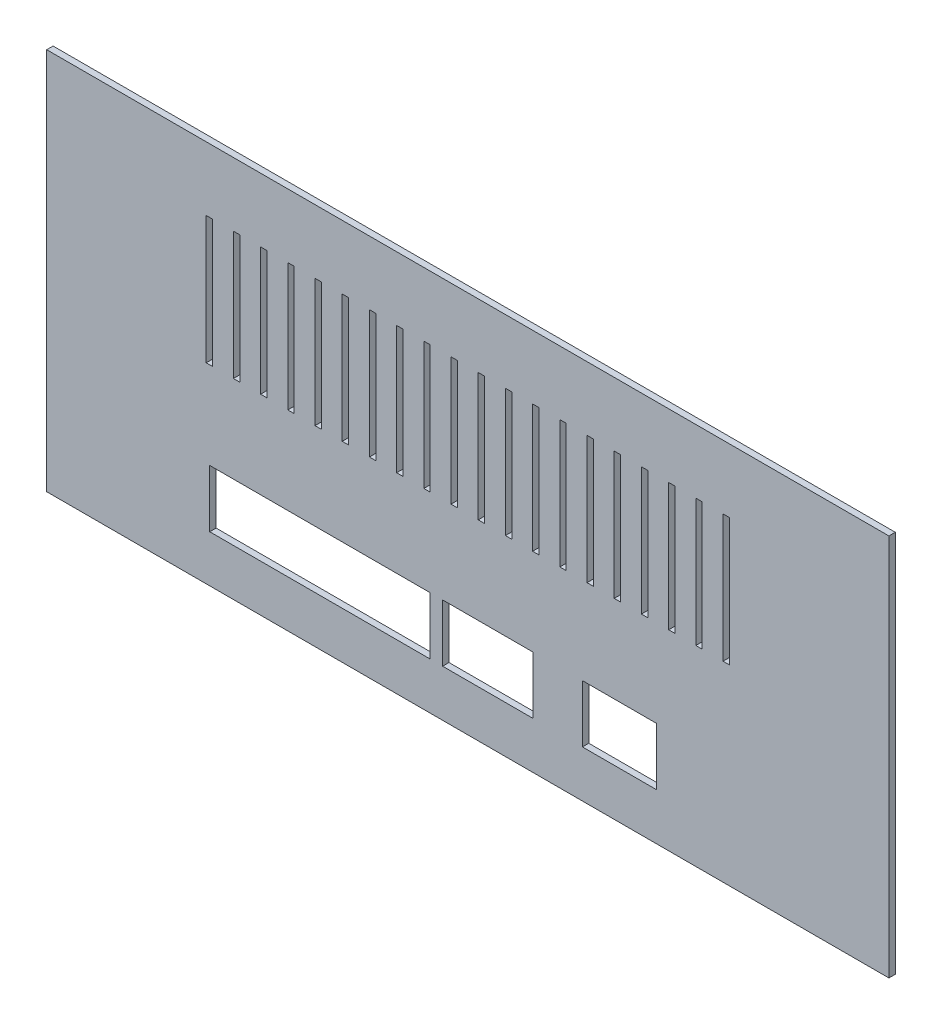
from build123d import *

# Parameters (mm, degrees)
SKETCH1_W           = 132
SKETCH1_H           = 60
BOSS_EXTRUDE1_DEPTH = 1
SKETCH4_W           = 11.62
SKETCH4_H           = 9
SKETCH4_W_2         = 14.16
SKETCH4_W_3         = 34.5
CUT_EXTRUDE3_DEPTH  = 2
SKETCH11_W          = 1
SKETCH11_H          = 20
CUT_EXTRUDE6_DEPTH  = 2


with BuildPart() as part:
    # Sketch1 → Boss-Extrude1 (new body)
    with BuildSketch(Plane.XY):
        with Locations((17.755849622, 9.633412311)):
            Rectangle(SKETCH1_W, SKETCH1_H)
    extrude(amount=BOSS_EXTRUDE1_DEPTH)

    # Sketch4 → Cut-Extrude3 (cut, through all)
    with BuildSketch(Plane(origin=(0, 0, 0), x_dir=(-1, 0, 0), z_dir=(0, 0, -1))):
        with Locations((-41.525849622, -8.521305626)):
            Rectangle(SKETCH4_W, SKETCH4_H)
        with Locations((-20.885849622, -8.521305626)):
            Rectangle(SKETCH4_W_2, SKETCH4_H)
        with Locations((5.444150378, -8.521305626)):
            Rectangle(SKETCH4_W_3, SKETCH4_H)
    extrude(amount=-CUT_EXTRUDE3_DEPTH, mode=Mode.SUBTRACT)

    # Sketch11 → Cut-Extrude6 (cut, through all)
    with BuildSketch(Plane(origin=(0, 0, 0), x_dir=(-1, 0, 0), z_dir=(0, 0, -1))):
        with Locations((-53.992691727, 19.633412311)):
            Rectangle(SKETCH11_W, SKETCH11_H)
        with Locations((-58.255849622, 19.633412311)):
            Rectangle(SKETCH11_W, SKETCH11_H)
        with Locations((-49.729533832, 19.633412311)):
            Rectangle(SKETCH11_W, SKETCH11_H)
        with Locations((-45.466375937, 19.633412311)):
            Rectangle(SKETCH11_W, SKETCH11_H)
        with Locations((-41.203218043, 19.633412311)):
            Rectangle(SKETCH11_W, SKETCH11_H)
        with Locations((-36.940060148, 19.633412311)):
            Rectangle(SKETCH11_W, SKETCH11_H)
        with Locations((-32.676902253, 19.633412311)):
            Rectangle(SKETCH11_W, SKETCH11_H)
        with Locations((-28.413744358, 19.633412311)):
            Rectangle(SKETCH11_W, SKETCH11_H)
        with Locations((-24.150586464, 19.633412311)):
            Rectangle(SKETCH11_W, SKETCH11_H)
        with Locations((-19.887428569, 19.633412311)):
            Rectangle(SKETCH11_W, SKETCH11_H)
        with Locations((-15.624270674, 19.633412311)):
            Rectangle(SKETCH11_W, SKETCH11_H)
        with Locations((-11.36111278, 19.633412311)):
            Rectangle(SKETCH11_W, SKETCH11_H)
        with Locations((-7.097954885, 19.633412311)):
            Rectangle(SKETCH11_W, SKETCH11_H)
        with Locations((-2.83479699, 19.633412311)):
            Rectangle(SKETCH11_W, SKETCH11_H)
        with Locations((1.428360905, 19.633412311)):
            Rectangle(SKETCH11_W, SKETCH11_H)
        with Locations((5.691518799, 19.633412311)):
            Rectangle(SKETCH11_W, SKETCH11_H)
        with Locations((9.954676694, 19.633412311)):
            Rectangle(SKETCH11_W, SKETCH11_H)
        with Locations((14.217834589, 19.633412311)):
            Rectangle(SKETCH11_W, SKETCH11_H)
        with Locations((18.480992484, 19.633412311)):
            Rectangle(SKETCH11_W, SKETCH11_H)
        with Locations((22.744150378, 19.633412311)):
            Rectangle(SKETCH11_W, SKETCH11_H)
    extrude(amount=-CUT_EXTRUDE6_DEPTH, mode=Mode.SUBTRACT)


solid = part.part
